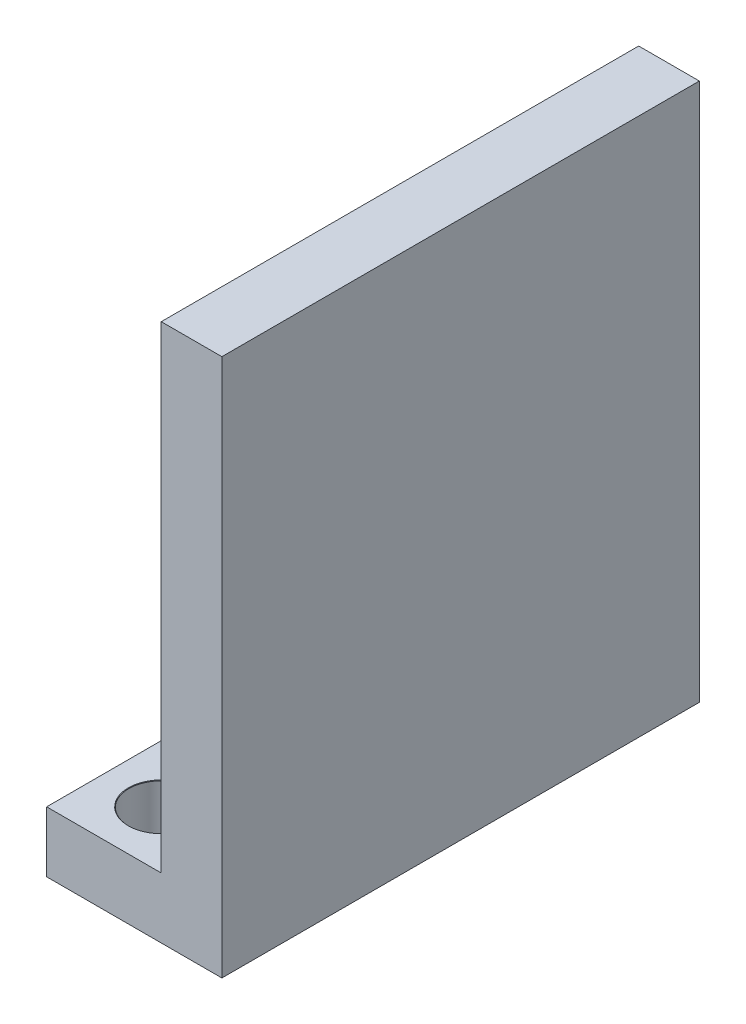
from build123d import *

# Parameters (mm, degrees)
SKETCH1_W                      = 9.175
SKETCH1_H                      = 25
BOSS_EXTRUDE1_DEPTH            = 3.175
SKETCH2_W                      = 3.175
SKETCH2_H                      = 25
BOSS_EXTRUDE2_DEPTH            = 25
M3_CLEARANCE_HOLE1_D           = 3.4
M3_CLEARANCE_HOLE1_CSINK_D     = 3.45
M3_CLEARANCE_HOLE1_CSINK_ANGLE = 90


with BuildPart() as part:
    # Sketch1 → Boss-Extrude1 (new body)
    with BuildSketch(Plane(origin=(0, 0, 0), x_dir=(1, 0, 0), z_dir=(0, 1, 0))):
        with Locations((4.5875, 12.5)):
            Rectangle(SKETCH1_W, SKETCH1_H)
    extrude(amount=BOSS_EXTRUDE1_DEPTH)

    # Sketch2 → Boss-Extrude2 (add)
    with BuildSketch(Plane(origin=(0, 3.175, 0), x_dir=(1, 0, 0), z_dir=(0, 1, 0))):
        with Locations((7.5875, 12.5)):
            Rectangle(SKETCH2_W, SKETCH2_H)
    extrude(amount=BOSS_EXTRUDE2_DEPTH)

    # M3 Clearance Hole1 (through all)
    with Locations(Plane(origin=(0, 3.175, 0), x_dir=(1, 0, 0), z_dir=(0, 1, 0))):
        with Locations((3, 22), (3, 3)):
            CounterSinkHole(M3_CLEARANCE_HOLE1_D / 2, M3_CLEARANCE_HOLE1_CSINK_D / 2, counter_sink_angle=M3_CLEARANCE_HOLE1_CSINK_ANGLE)


solid = part.part
